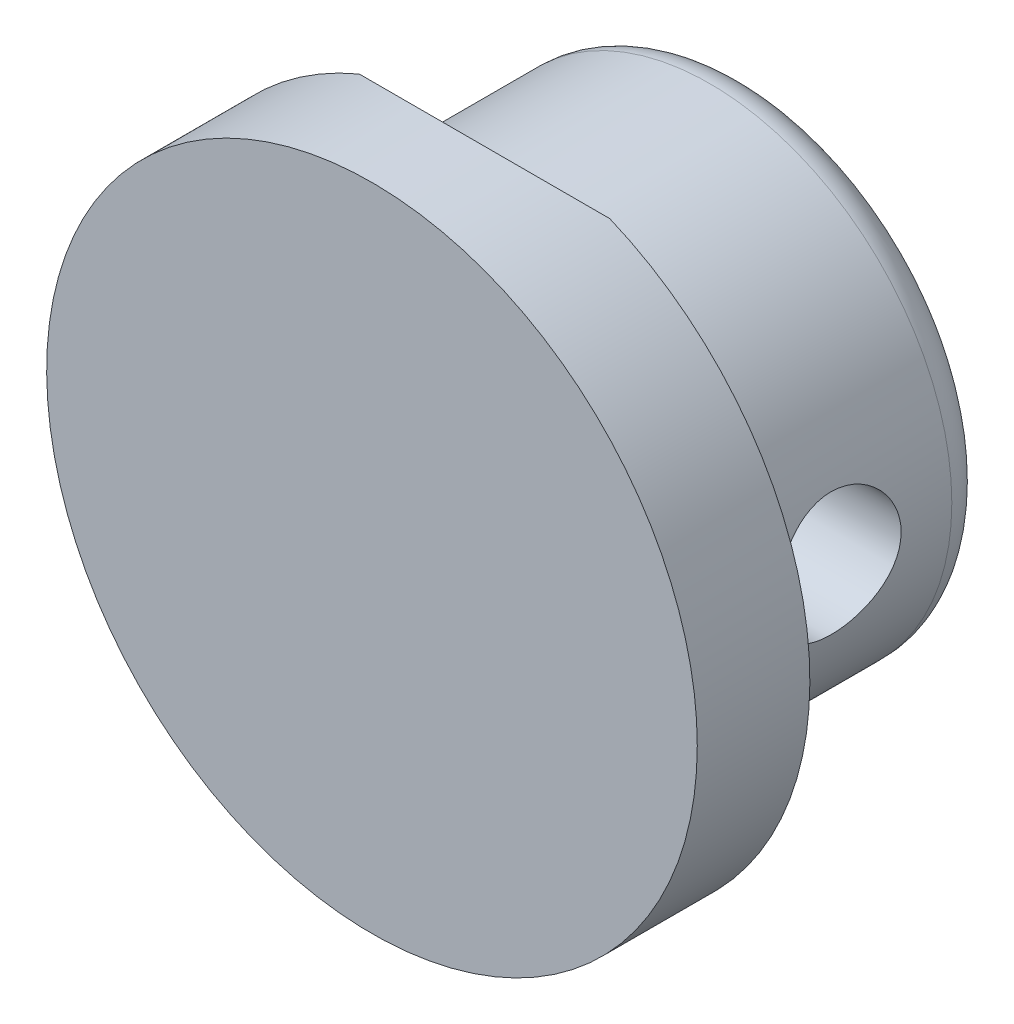
from build123d import *

# Parameters (mm, degrees)
SKETCH_1_R               = 6.45
EXTRUDE_1_DEPTH          = 7
SKETCH_2_W               = 29.5
SKETCH_2_H               = 18
EXTRUDE_2_DEPTH          = 3
EXTRUDE_START            = 14.75
SKETCH_3_R               = 1.65
EXTRUDE_3_DEPTH          = 5
EXTRUDE_START_2          = -14.75
SKETCH_3_2_R             = 1.65
EXTRUDE_4_DEPTH          = 5
EXTRUDE_5_DEPTH          = 10
FILLET_1_R               = 5
SKETCH_5_R               = 2.5
CUT_EXTRUDE_1_DEPTH      = 11
CHAMFER_1_SIZE           = 1
CHAMFER_2_SIZE           = 1
CUT_EXTRUDE_2_DEPTH      = 15.75
CUT_EXTRUDE_2_DEPTH_BACK = 15.75
FILLET_2_R               = 1
SKETCH_7_OUTSIDE_W       = 42.194
SKETCH_7_OUTSIDE_H       = 45.694
SKETCH_7_OUTSIDE_R       = 8.66784174
CUT_EXTRUDE_3_DEPTH      = 1
CUT_EXTRUDE_3_DEPTH_BACK = 31


with BuildPart() as part:
    # ｽｹｯﾁ1 → ﾎﾞｽ - 押し出し1 (new body)
    with BuildSketch(Plane.XY):
        Circle(SKETCH_1_R)
    extrude(amount=EXTRUDE_1_DEPTH)

    # ｽｹｯﾁ2 → ﾎﾞｽ - 押し出し2 (add)
    with BuildSketch(Plane.XY.offset(7)):
        Rectangle(SKETCH_2_W, SKETCH_2_H)
    extrude(amount=EXTRUDE_2_DEPTH)

    # ｽｹｯﾁ3 → ﾎﾞｽ - 押し出し3 (add)
    with BuildSketch(Plane(origin=(0, 0, 0), x_dir=(0, 0, -1), z_dir=(1, 0, 0)).offset(EXTRUDE_START)):
        with BuildLine():
            Line((-10, 9), (-23.333333333, 13.714045208))
            ThreePointArc((-23.333333333, 13.714045208), (-29.386897866, 11.398984601), (-28.069570429, 5.053135753))
            Line((-28.069570429, 5.053135753), (-10, -9))
            Line((-10, -9), (-10, 9))
        make_face()
        with Locations((-25, 9)):
            Circle(SKETCH_3_R, mode=Mode.SUBTRACT)
    extrude(amount=-EXTRUDE_3_DEPTH)

    # ｽｹｯﾁ3<2> → ﾎﾞｽ - 押し出し4 (add)
    with BuildSketch(Plane(origin=(0, 0, 0), x_dir=(0, 0, -1), z_dir=(1, 0, 0)).offset(EXTRUDE_START_2)):
        with BuildLine():
            Line((-10, 9), (-23.333333333, 13.714045208))
            ThreePointArc((-23.333333333, 13.714045208), (-29.386897866, 11.398984601), (-28.069570429, 5.053135753))
            Line((-28.069570429, 5.053135753), (-10, -9))
            Line((-10, -9), (-10, 9))
        make_face()
        with Locations((-25, 9)):
            Circle(SKETCH_3_2_R, mode=Mode.SUBTRACT)
    extrude(amount=EXTRUDE_4_DEPTH)

    # ｽｹｯﾁ4 → ﾎﾞｽ - 押し出し5 (add)
    with BuildSketch(Plane.XZ.offset(9)):
        Polygon((-14.75, 7), (14.75, 7), (14.75, 10), (9.75, 10), (-9.75, 10), (-14.75, 10), align=None)
    extrude(amount=EXTRUDE_5_DEPTH)

    # ﾌｨﾚｯﾄ1
    fillet_1_edges = [part.edges().sort_by_distance(p)[0] for p in [
        (-14.75, -19, 8.5),
        (14.75, -19, 8.5),
    ]]
    fillet(fillet_1_edges, radius=FILLET_1_R)

    # ｽｹｯﾁ5 → ｶｯﾄ - 押し出し1 (cut, through all)
    with BuildSketch(Plane.XY.offset(10)):
        with Locations((0, -14)):
            Circle(SKETCH_5_R)
        with Locations((-9.75, -14)):
            Circle(SKETCH_5_R)
        with Locations((9.75, -14)):
            Circle(SKETCH_5_R)
    extrude(amount=-CUT_EXTRUDE_1_DEPTH, mode=Mode.SUBTRACT)

    # 面取り1
    chamfer_1_edges = [part.edges().sort_by_distance(p)[0] for p in [
        (7.25, -14, 7),
        (7.25, -14, 10),
        (-12.25, -14, 7),
        (-12.25, -14, 10),
        (-2.5, -14, 7),
        (-2.5, -14, 10),
    ]]
    chamfer(chamfer_1_edges, length=CHAMFER_1_SIZE)

    # 面取り2
    chamfer_2_edges = [part.edges().sort_by_distance(p)[0] for p in [
        (-14.75, 9, 8.5),
        (0, 9, 7),
        (14.75, 9, 8.5),
        (-14.75, 11.357022604, 16.666666667),
        (-14.75, 11.398984601, 29.386897866),
        (-14.75, -1.973432123, 19.034785215),
        (14.75, 11.357022604, 16.666666667),
        (14.75, 11.398984601, 29.386897866),
        (14.75, -1.973432123, 19.034785215),
    ]]
    chamfer(chamfer_2_edges, length=CHAMFER_2_SIZE)

    # ｽｹｯﾁ6 → ｶｯﾄ - 押し出し2 (cut, two sides)
    with BuildSketch(Plane(origin=(0, 0, 0), x_dir=(0, 0, -1), z_dir=(1, 0, 0))) as cut_extrude_2_sk:
        with BuildLine():
            Line((-5.428941916, -0.825), (-5.905255888, 0))
            Line((-5.905255888, 0), (-5.428941916, 0.825))
            ThreePointArc((-5.428941916, 0.825), (-2.35, 0), (-5.428941916, -0.825))
        make_face()
    extrude(amount=CUT_EXTRUDE_2_DEPTH, mode=Mode.SUBTRACT)
    extrude(cut_extrude_2_sk.sketch, amount=-CUT_EXTRUDE_2_DEPTH_BACK, mode=Mode.SUBTRACT)

    # ﾌｨﾚｯﾄ2
    fillet_2_edges = [part.edges().sort_by_distance(p)[0] for p in [
        (-6.45, 0, 0),
    ]]
    fillet(fillet_2_edges, radius=FILLET_2_R)

    # ｽｹｯﾁ7 outside → ｶｯﾄ - 押し出し3 (cut, two sides)
    with BuildSketch(Plane(origin=(0, 0, 0), x_dir=(-1, 0, 0), z_dir=(0, 0, -1))) as cut_extrude_3_sk:
        with Locations((0, -2.5)):
            Rectangle(SKETCH_7_OUTSIDE_W, SKETCH_7_OUTSIDE_H)
        Circle(SKETCH_7_OUTSIDE_R, mode=Mode.SUBTRACT)
    extrude(amount=CUT_EXTRUDE_3_DEPTH, mode=Mode.SUBTRACT)
    extrude(cut_extrude_3_sk.sketch, amount=-CUT_EXTRUDE_3_DEPTH_BACK, mode=Mode.SUBTRACT)


solid = part.part
